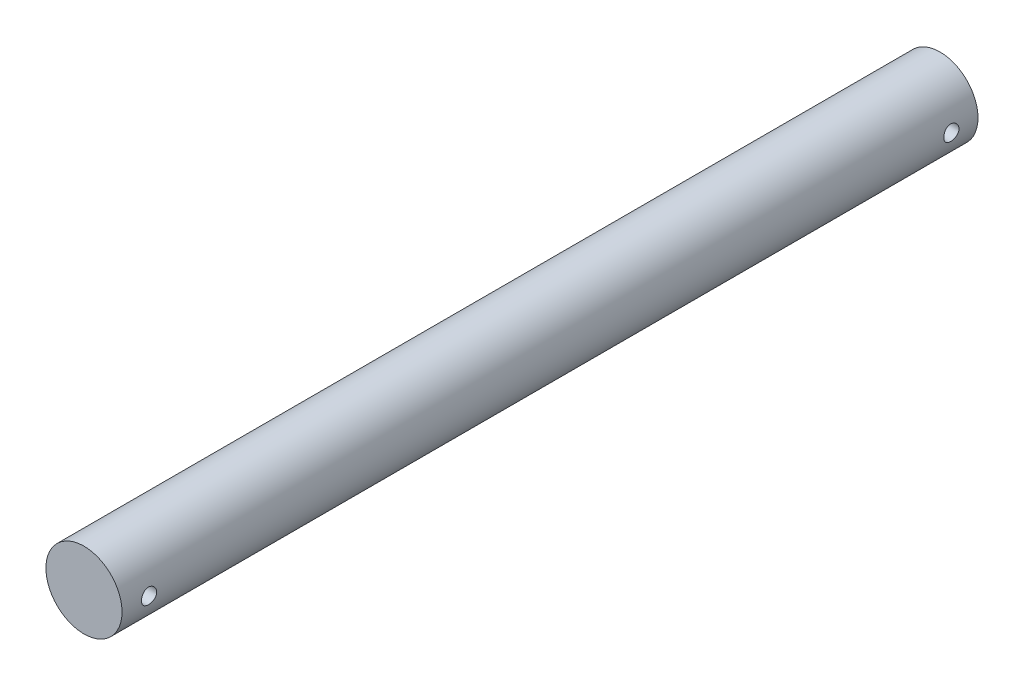
from build123d import *

# Parameters (mm, degrees)
SKETCH1_R               = 20
BOSS_EXTRUDE1_DEPTH     = 450
SKETCH2_R               = 4
CUT_EXTRUDE1_DEPTH      = 21
CUT_EXTRUDE1_DEPTH_BACK = 21


with BuildPart() as part:
    # Sketch1 → Boss-Extrude1 (new body)
    with BuildSketch(Plane.XY):
        Circle(SKETCH1_R)
    extrude(amount=BOSS_EXTRUDE1_DEPTH)

    # Sketch2 → Cut-Extrude1 (cut, two sides)
    with BuildSketch(Plane(origin=(0, 0, 0), x_dir=(0, 0, -1), z_dir=(1, 0, 0))) as cut_extrude1_sk:
        with Locations((-435.75, 0)):
            Circle(SKETCH2_R)
        with Locations((-14, 0)):
            Circle(SKETCH2_R)
    extrude(amount=CUT_EXTRUDE1_DEPTH, mode=Mode.SUBTRACT)
    extrude(cut_extrude1_sk.sketch, amount=-CUT_EXTRUDE1_DEPTH_BACK, mode=Mode.SUBTRACT)


solid = part.part
